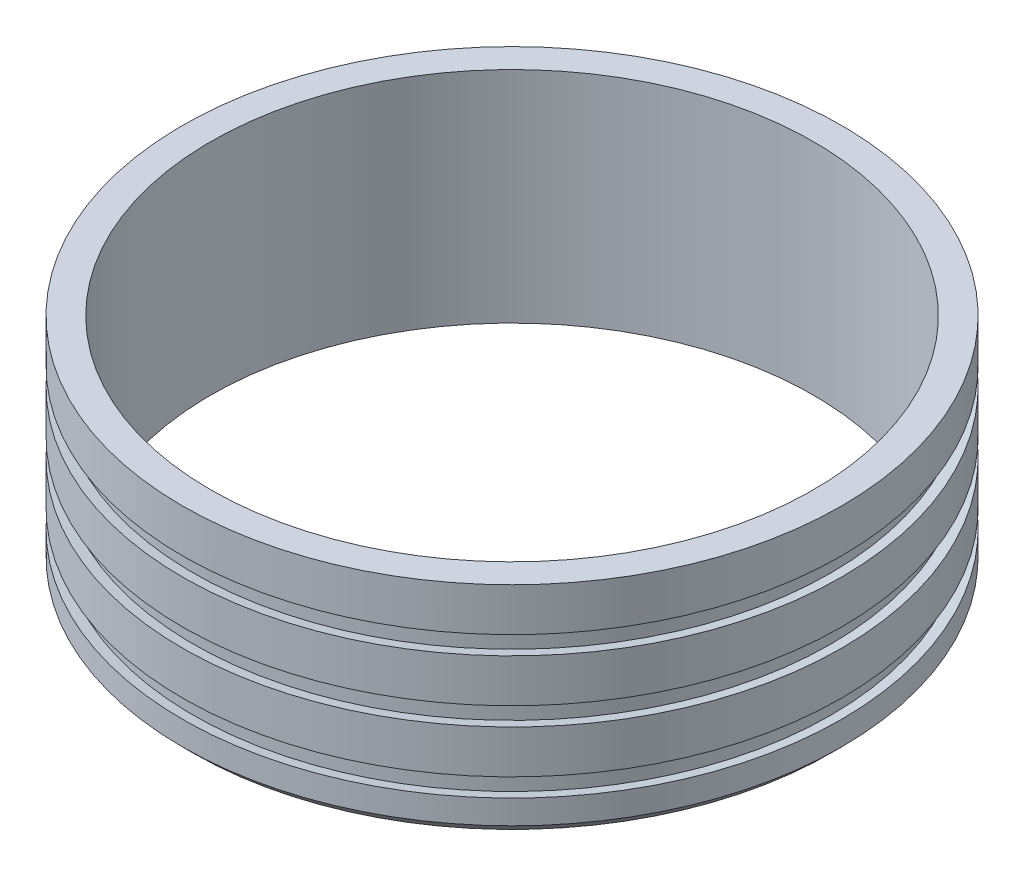
from build123d import *

# Parameters (mm, degrees)
SKETCH1_R           = 76.25
SKETCH1_R_2         = 69.75
BOSS_EXTRUDE1_DEPTH = 50.8
CHAMFER1_SIZE       = 2.5


with BuildPart() as part:
    # Sketch1 → Boss-Extrude1 (new body)
    with BuildSketch(Plane(origin=(0, 0, 0), x_dir=(1, 0, 0), z_dir=(0, 1, 0))):
        Circle(SKETCH1_R)
        Circle(SKETCH1_R_2, mode=Mode.SUBTRACT)
    extrude(amount=BOSS_EXTRUDE1_DEPTH)

    # Sketch2 → Cut-Revolve1 (revolve, cut)
    with BuildSketch(Plane.XY):
        Polygon((-76.25, 40.8), (-76.25, 36.55), (-73.75, 36.109182548), (-73.75, 41.240817452), align=None)
        Polygon((-73.75, 26.990817452), (-73.75, 21.859182548), (-76.25, 22.3), (-76.25, 26.55), align=None)
        Polygon((-73.75, 12.740817452), (-73.75, 7.609182548), (-76.25, 8.05), (-76.25, 12.3), align=None)
    revolve(axis=Axis((0, 0, 0), (0, 1, 0)), mode=Mode.SUBTRACT)

    # Chamfer1
    chamfer1_edges = [part.edges().sort_by_distance(p)[0] for p in [
        (-76.25, 0, 0),
    ]]
    chamfer(chamfer1_edges, length=CHAMFER1_SIZE)


solid = part.part
